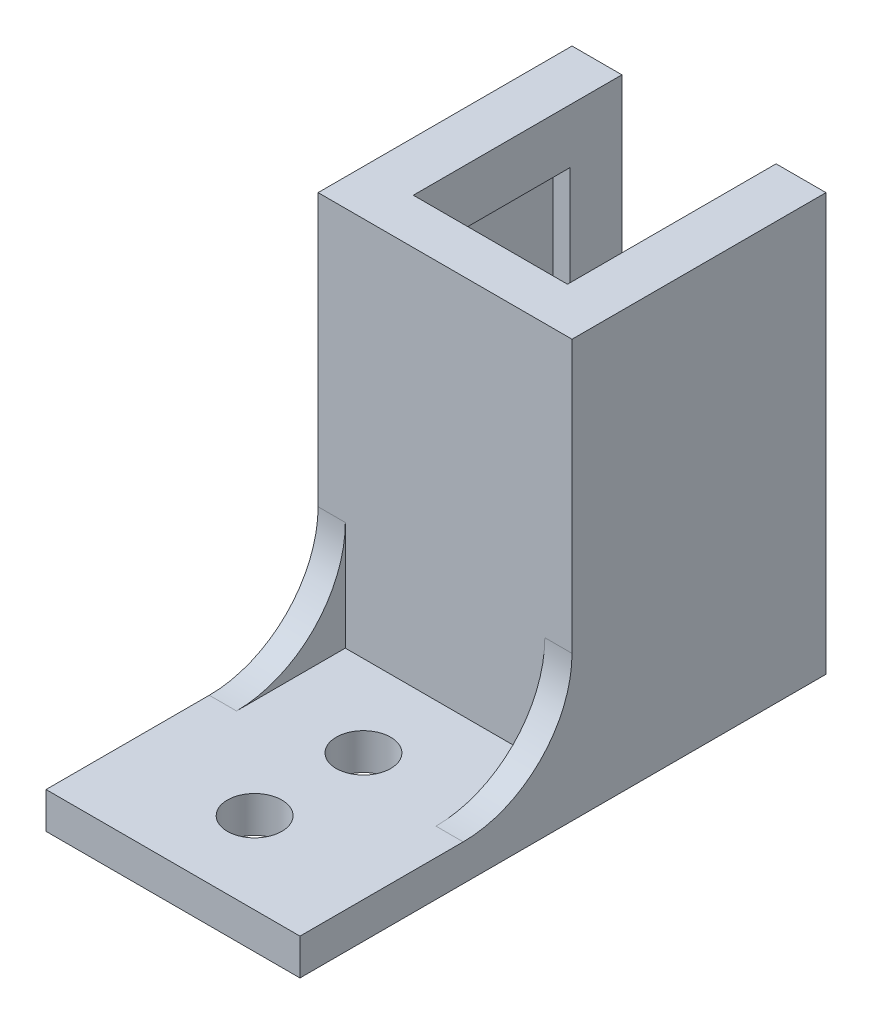
from build123d import *

# Parameters (mm, degrees)
SKETCH1_W           = 14
SKETCH1_H           = 23
BOSS_EXTRUDE1_DEPTH = 14
SKETCH2_W           = 10.4
SKETCH2_H           = 8.65
SKETCH2_W_2         = 8.5
SKETCH2_H_2         = 2.85
CUT_EXTRUDE1_DEPTH  = 20
SKETCH3_W           = 14
SKETCH3_H           = 15
SKETCH3_R           = 1.5
BOSS_EXTRUDE2_DEPTH = 2
BOSS_EXTRUDE3_DEPTH = 1.5
SKETCH5_W           = 8.5
SKETCH5_H           = 11.5
CUT_EXTRUDE2_DEPTH  = 4


with BuildPart() as part:
    # Sketch1 → Boss-Extrude1 (new body)
    with BuildSketch(Plane.XY):
        Rectangle(SKETCH1_W, SKETCH1_H)
    extrude(amount=BOSS_EXTRUDE1_DEPTH)

    # Sketch2 → Cut-Extrude1 (cut)
    with BuildSketch(Plane.XZ.offset(11.5)):
        with Locations((0, 7.175)):
            Rectangle(SKETCH2_W, SKETCH2_H)
        with Locations((0, 1.425)):
            Rectangle(SKETCH2_W_2, SKETCH2_H_2)
    extrude(amount=-CUT_EXTRUDE1_DEPTH, mode=Mode.SUBTRACT)

    # Sketch3 → Boss-Extrude2 (add)
    with BuildSketch(Plane.XZ.offset(11.5)):
        with Locations((0, 21.5)):
            Rectangle(SKETCH3_W, SKETCH3_H)
        with Locations((0, 18.5)):
            Circle(SKETCH3_R, mode=Mode.SUBTRACT)
        with Locations((0, 24.5)):
            Circle(SKETCH3_R, mode=Mode.SUBTRACT)
    extrude(amount=-BOSS_EXTRUDE2_DEPTH)

    # Sketch4 → Boss-Extrude3 (add)
    with BuildSketch(Plane.ZY.offset(7)):
        with BuildLine():
            Line((14, -3.5), (14, -9.5))
            Line((14, -9.5), (20, -9.5))
            ThreePointArc((20, -9.5), (15.757359313, -7.742640687), (14, -3.5))
        make_face()
    boss_extrude3 = extrude(amount=-BOSS_EXTRUDE3_DEPTH)

    # Mirror1: Boss-Extrude3 across plane
    add(boss_extrude3.mirror(Plane(origin=(0, 0, 0), x_dir=(0, 0, 1), z_dir=(1, 0, 0))))

    # Sketch5 → Cut-Extrude2 (cut, through all)
    with BuildSketch(Plane.XZ.offset(-8.5)):
        with Locations((0, 5.75)):
            Rectangle(SKETCH5_W, SKETCH5_H)
    extrude(amount=-CUT_EXTRUDE2_DEPTH, mode=Mode.SUBTRACT)


solid = part.part
